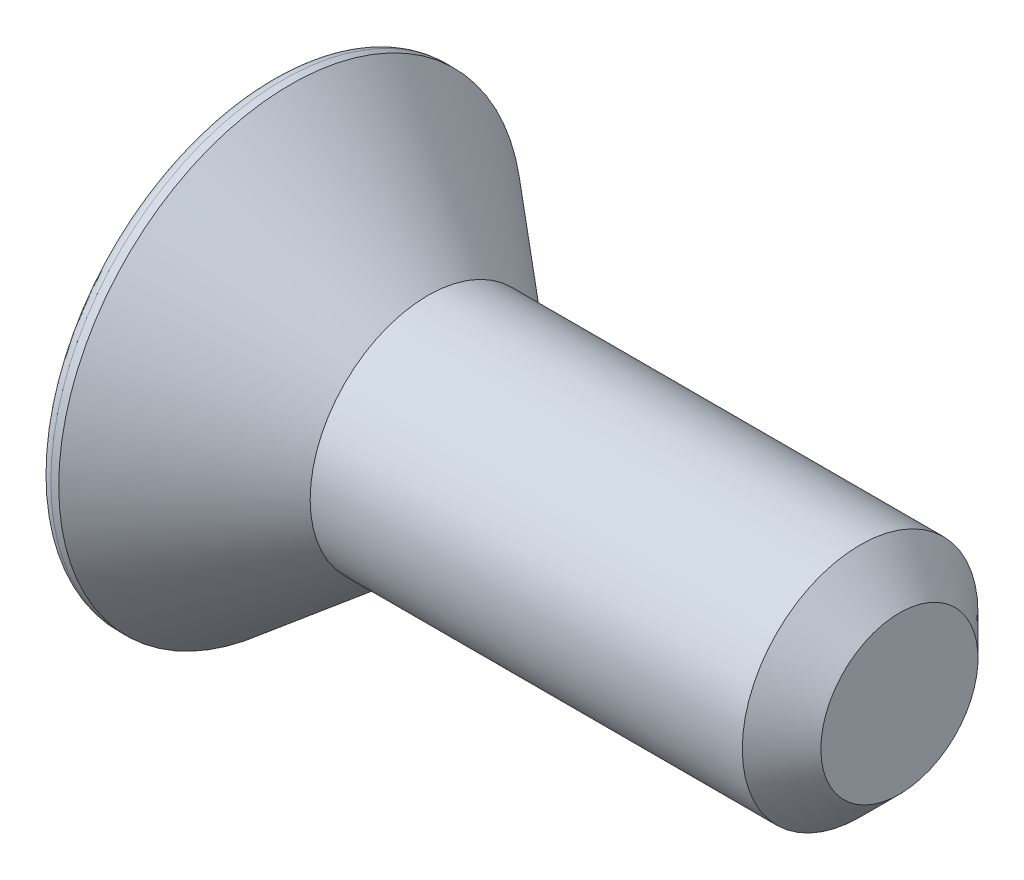
from build123d import *

# Parameters (mm, degrees)
CUT_EXTRUDE_1_DEPTH = 3
FILLET_1_R          = 0.3
CHAMFER_1_SIZE      = 1


with BuildPart() as part:
    # Эскиз1 → Повернуть1 (revolve)
    with BuildSketch(Plane.XY, mode=Mode.PRIVATE) as revolve_1_sk:
        Polygon((0, 0), (0, 5.9), (0.5, 5.9), (4, 3), (16, 3), (16, 0), align=None)
    revolve(revolve_1_sk.sketch.rotate(Axis((0, 0, 0), (1, 0, 0)), 90), axis=Axis((0, 0, 0), (1, 0, 0)))  # turned: the seam where the file's is

    # Эскиз2 → Вырез-Вытянуть1 (cut)
    with BuildSketch(Plane.ZY):
        Polygon((1.154700538, 2), (-1.154700538, 2), (-2.309401077, 0), (-1.154700538, -2), (1.154700538, -2), (2.309401077, 0), align=None)
    extrude(amount=-CUT_EXTRUDE_1_DEPTH, mode=Mode.SUBTRACT)

    # Скругление1
    fillet_1_edges = [part.edges().sort_by_distance(p)[0] for p in [
        (0, 0, -5.9),
    ]]
    fillet(fillet_1_edges, radius=FILLET_1_R)

    # Фаска1
    chamfer_1_edges = [part.edges().sort_by_distance(p)[0] for p in [
        (16, 0, -3),
    ]]
    chamfer(chamfer_1_edges, length=CHAMFER_1_SIZE)


solid = part.part
